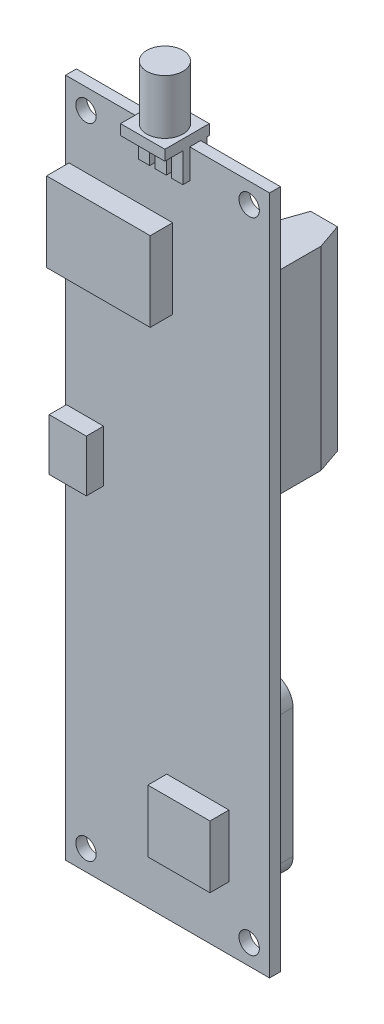
from build123d import *

# Parameters (mm, degrees)
SKETCH3_W            = 1.6002
SKETCH3_H            = 100
BOSS_EXTRUDE1_DEPTH  = 30
SKETCH5_R            = 1.5
SCREW_HOLES_DEPTH    = 13.39
SKETCH7_W            = 6.477
SKETCH7_H            = 28.575
BOSS_EXTRUDE2_DEPTH  = 9.906
CUT_EXTRUDE1_REACH   = 91.18
SKETCH9_R            = 6.0325
BOSS_EXTRUDE3_DEPTH  = 6.35
FILLET1_R            = 0.762
SKETCH10_W           = 25.0698
SKETCH10_H           = 25.0698
BOSS_EXTRUDE4_DEPTH  = 4.318
FILLET2_R            = 3.048
SKETCH11_W           = 19.558
SKETCH11_H           = 19.558
STICKER_DEPTH        = 0.0254
SKETCH12_W           = 15.24
SKETCH12_H           = 11.684
BIG_CHIP_DEPTH       = 3.302
SKETCH13_W           = 9.144
SKETCH13_H           = 9.144
UBLOX_CHIP_DEPTH     = 2.794
SKETCH14_W           = 6.5278
SKETCH14_H           = 6.5278
BOSS_EXTRUDE8_DEPTH  = 1.524
SKETCH15_R           = 2.667
BOSS_EXTRUDE9_DEPTH  = 8.001
SKETCH17_W           = 1.651
SKETCH17_H           = 1.016
BOSS_EXTRUDE10_DEPTH = 4.318
SKETCH18_W           = 1.651
SKETCH18_H           = 0.9652
BOSS_EXTRUDE11_DEPTH = 4.318
SKETCH19_W           = 5.461
SKETCH19_H           = 7.62
USB_CONNECTOR_DEPTH  = 2.54


with BuildPart() as part:
    # Sketch3 → Boss-Extrude1 (new body)
    with BuildSketch(Plane(origin=(0, 0, 0), x_dir=(0, 0, -1), z_dir=(1, 0, 0))):
        with Locations((-0.8001, -50)):
            Rectangle(SKETCH3_W, SKETCH3_H)
    extrude(amount=BOSS_EXTRUDE1_DEPTH)

    # Sketch5 → Screw-Holes (cut)
    with BuildSketch(Plane.XY.offset(1.6002)):
        with Locations((27, -3)):
            Circle(SKETCH5_R)
        with Locations((3, -3)):
            Circle(SKETCH5_R)
        with Locations((3, -97)):
            Circle(SKETCH5_R)
        with Locations((27, -97)):
            Circle(SKETCH5_R)
    extrude(amount=-SCREW_HOLES_DEPTH, mode=Mode.SUBTRACT)

    # Sketch7 → Boss-Extrude2 (add)
    with BuildSketch(Plane(origin=(0, 0, 0), x_dir=(-1, 0, 0), z_dir=(0, 0, -1))):
        with Locations((-26.5075, -25.1079)):
            Rectangle(SKETCH7_W, SKETCH7_H)
    extrude(amount=BOSS_EXTRUDE2_DEPTH)

    # Sketch8 → Cut-Extrude1 (cut, up to next)
    with BuildSketch(Plane(origin=(0, -10.8204, 0), x_dir=(1, 0, 0), z_dir=(0, 1, 0)), mode=Mode.PRIVATE) as cut_extrude1_sk1:
        Polygon((28.476, 9.906), (29.746, 6.223), (29.746, 9.906), align=None)
    cut_extrude1_tool1 = extrude(cut_extrude1_sk1.sketch, amount=-CUT_EXTRUDE1_REACH, mode=Mode.PRIVATE) & part.part
    add(cut_extrude1_tool1.solids().sort_by_distance((29.322667, -10.8204, -8.678333))[0], mode=Mode.SUBTRACT)
    # Sketch8 → Cut-Extrude1 (cut, up to next)
    with BuildSketch(Plane(origin=(0, -10.8204, 0), x_dir=(1, 0, 0), z_dir=(0, 1, 0)), mode=Mode.PRIVATE) as cut_extrude1_sk2:
        Polygon((23.269, 9.906), (23.269, 6.223), (24.539, 9.906), align=None)
    cut_extrude1_tool2 = extrude(cut_extrude1_sk2.sketch, amount=-CUT_EXTRUDE1_REACH, mode=Mode.PRIVATE) & part.part
    add(cut_extrude1_tool2.solids().sort_by_distance((23.692333, -10.8204, -8.678333))[0], mode=Mode.SUBTRACT)

    # Sketch9 → Boss-Extrude3 (add)
    with BuildSketch(Plane(origin=(0, 0, 0), x_dir=(-1, 0, 0), z_dir=(0, 0, -1))):
        with Locations((-12.3825, -34.29)):
            Circle(SKETCH9_R)
    extrude(amount=BOSS_EXTRUDE3_DEPTH)

    # Fillet1
    fillet1_edges = [part.edges().sort_by_distance(p)[0] for p in [
        (18.415, -34.29, -6.35),
    ]]
    fillet(fillet1_edges, radius=FILLET1_R)

    # Sketch10 → Boss-Extrude4 (add)
    with BuildSketch(Plane(origin=(0, 0, 0), x_dir=(-1, 0, 0), z_dir=(0, 0, -1))):
        with Locations((-15, -79.2101)):
            Rectangle(SKETCH10_W, SKETCH10_H)
    extrude(amount=BOSS_EXTRUDE4_DEPTH)

    # Fillet2
    fillet2_edges = [part.edges().sort_by_distance(p)[0] for p in [
        (2.4651, -91.745, -2.159),
        (2.4651, -66.6752, -2.159),
        (27.5349, -66.6752, -2.159),
        (27.5349, -91.745, -2.159),
    ]]
    fillet(fillet2_edges, radius=FILLET2_R)

    # Sketch11 → Sticker (add)
    with BuildSketch(Plane(origin=(0, 0, -4.318), x_dir=(-1, 0, 0), z_dir=(0, 0, -1))):
        with Locations((-15, -79.2101)):
            Rectangle(SKETCH11_W, SKETCH11_H)
    extrude(amount=STICKER_DEPTH)

    # Sketch12 → Big chip (add)
    with BuildSketch(Plane.XY.offset(1.6002)):
        with Locations((8.128, -16.764)):
            Rectangle(SKETCH12_W, SKETCH12_H)
    extrude(amount=BIG_CHIP_DEPTH)

    # Sketch13 → ublox chip (add)
    with BuildSketch(Plane.XY.offset(1.6002)):
        with Locations((19.459, -86.157)):
            Rectangle(SKETCH13_W, SKETCH13_H)
    extrude(amount=UBLOX_CHIP_DEPTH)

    # Sketch14 → Boss-Extrude8 (add)
    with BuildSketch(Plane(origin=(0, 0, 0), x_dir=(1, 0, 0), z_dir=(0, 1, 0))):
        with Locations((15, -1.9939)):
            Rectangle(SKETCH14_W, SKETCH14_H)
    extrude(amount=BOSS_EXTRUDE8_DEPTH)

    # Sketch15 → Boss-Extrude9 (add)
    with BuildSketch(Plane(origin=(0, 1.524, 0), x_dir=(1, 0, 0), z_dir=(0, 1, 0))):
        with Locations((15, -1.9939)):
            Circle(SKETCH15_R)
    extrude(amount=BOSS_EXTRUDE9_DEPTH)

    # Sketch17 → Boss-Extrude10 (add)
    with BuildSketch(Plane.XZ):
        with Locations((15, 2.1082)):
            Rectangle(SKETCH17_W, SKETCH17_H)
        with Locations((12.5616, 2.1082)):
            Rectangle(SKETCH17_W, SKETCH17_H)
        with Locations((17.4384, 2.1082)):
            Rectangle(SKETCH17_W, SKETCH17_H)
    extrude(amount=BOSS_EXTRUDE10_DEPTH)

    # Sketch18 → Boss-Extrude11 (add)
    with BuildSketch(Plane.XZ):
        with Locations((12.5616, -0.4826)):
            Rectangle(SKETCH18_W, SKETCH18_H)
        with Locations((17.4384, -0.4826)):
            Rectangle(SKETCH18_W, SKETCH18_H)
    extrude(amount=BOSS_EXTRUDE11_DEPTH)

    # Sketch19 → USB connector (add)
    with BuildSketch(Plane.XY.offset(1.6002)):
        with Locations((2.8575, -45.72)):
            Rectangle(SKETCH19_W, SKETCH19_H)
    extrude(amount=USB_CONNECTOR_DEPTH)


solid = part.part
